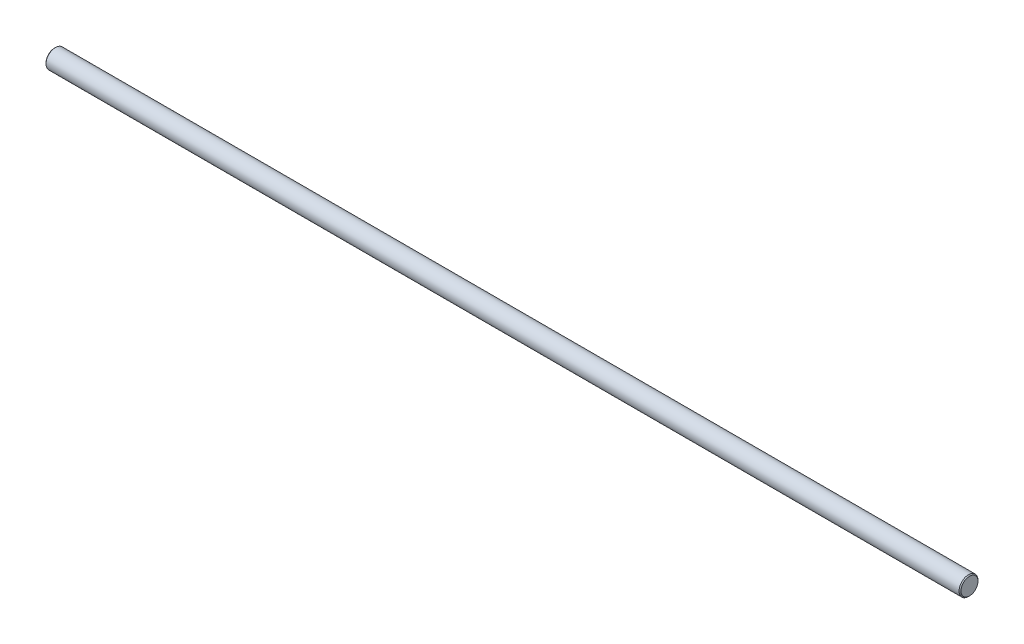
from build123d import *


with BuildPart() as part:
    # Sketch1 → Revolve1 (revolve)
    with BuildSketch(Plane.XY):
        Polygon((0, 0), (0, 4.5), (0.5, 5), (482.5, 5), (483, 4.5), (483, 0), align=None)
    revolve(axis=Axis((483, 0, 0), (-1, 0, 0)))


solid = part.part
